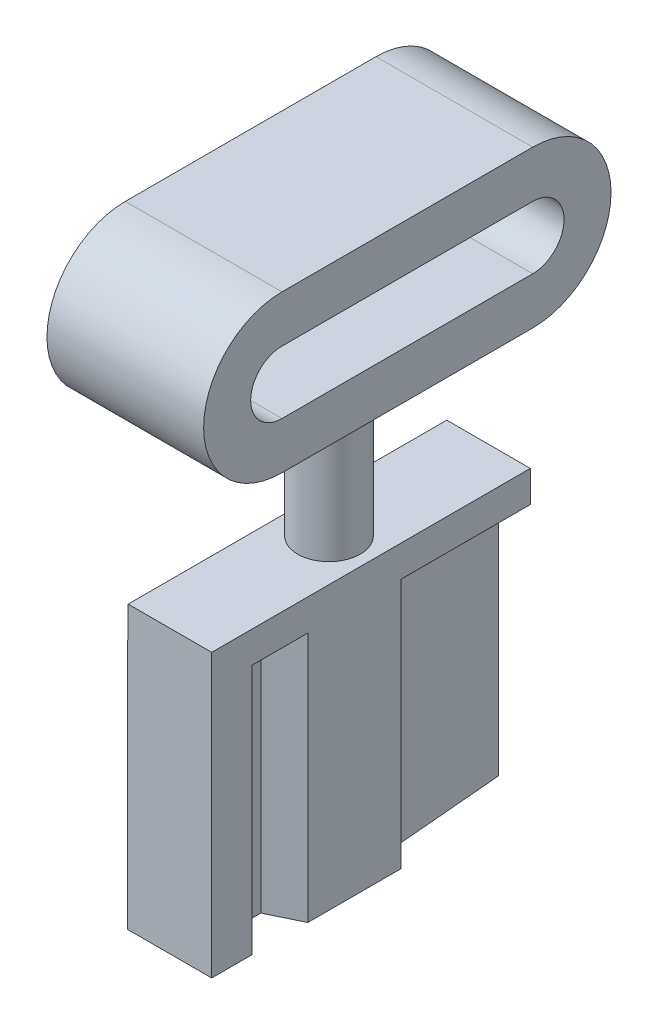
from build123d import *

# Parameters (mm, degrees)
BOSS_EXTRUDE1_DEPTH = 8
SKETCH8_W           = 2.666068872
SKETCH8_H           = 10.16707981
BOSS_EXTRUDE2_DEPTH = 1
SKETCH9_R           = 1
BOSS_EXTRUDE3_DEPTH = 5
BOSS_EXTRUDE4_DEPTH = 2.5


with BuildPart() as part:
    # Sketch7 → Boss-Extrude1 (new body)
    with BuildSketch(Plane(origin=(0, 0, 0), x_dir=(1, 0, 0), z_dir=(0, 1, 0))):
        Polygon((-1.340563115, -5.083539905), (-1.340563115, -1.49622437), (-0.25317284, -1.264277343), (-0.25317284, -0.218468371), (-1.12873384, 0.657092629), (-0.958485867, 5.083539905), (0.330534493, 5.083539905), (0.634548729, 1.544814198), (1.340563115, 0.95051095), (1.340563115, -2.018232649), (0.330534493, -2.504655426), (0.330534493, -3.289882138), (1.340563115, -3.793675787), (1.340563115, -5.083539905), align=None)
    extrude(amount=-BOSS_EXTRUDE1_DEPTH)

    # Sketch8 → Boss-Extrude2 (add)
    with BuildSketch(Plane(origin=(0, 0, 0), x_dir=(1, 0, 0), z_dir=(0, 1, 0))):
        with Locations((0.007528679, 0)):
            Rectangle(SKETCH8_W, SKETCH8_H)
    extrude(amount=BOSS_EXTRUDE2_DEPTH)

    # Sketch9 → Boss-Extrude3 (add)
    with BuildSketch(Plane(origin=(0, 1, 0), x_dir=(1, 0, 0), z_dir=(0, 1, 0))):
        Circle(SKETCH9_R)
    extrude(amount=BOSS_EXTRUDE3_DEPTH)

    # Sketch11 → Boss-Extrude4 (add, symmetric)
    with BuildSketch(Plane(origin=(0, 0, 0), x_dir=(0, 0, -1), z_dir=(1, 0, 0))):
        with BuildLine():
            Line((-4, 11), (4, 11))
            ThreePointArc((4, 11), (6.5, 8.5), (4, 6))
            Line((4, 6), (-4, 6))
            ThreePointArc((-4, 6), (-6.5, 8.5), (-4, 11))
        make_face()
        with BuildLine():
            Line((-4, 9.5), (4, 9.5))
            ThreePointArc((4, 9.5), (5, 8.5), (4, 7.5))
            Line((4, 7.5), (-4, 7.5))
            ThreePointArc((-4, 7.5), (-5, 8.5), (-4, 9.5))
        make_face(mode=Mode.SUBTRACT)
    extrude(amount=BOSS_EXTRUDE4_DEPTH, both=True)


solid = part.part
